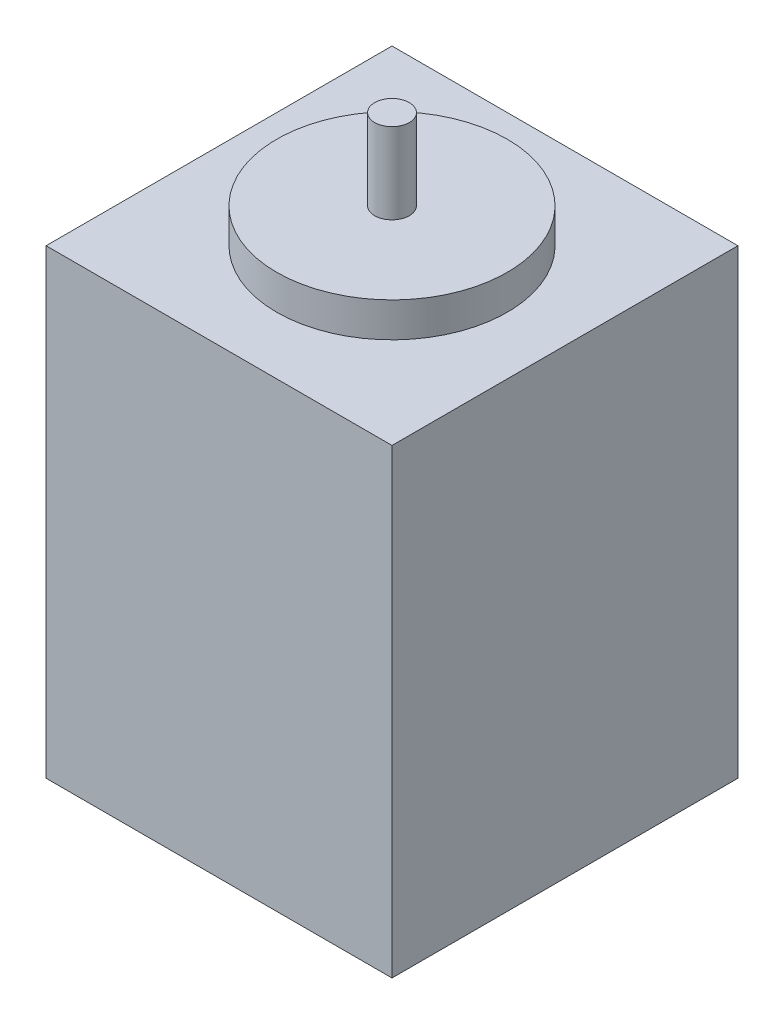
from build123d import *

# Parameters (mm, degrees)
SKETCH1_W           = 30
SKETCH1_H           = 30
BOSS_EXTRUDE1_DEPTH = 40
SKETCH2_R           = 1.5
BOSS_EXTRUDE2_DEPTH = 10
SKETCH4_R           = 10
BOSS_EXTRUDE3_DEPTH = 3


with BuildPart() as part:
    # Sketch1 → Boss-Extrude1 (new body)
    with BuildSketch(Plane(origin=(0, 0, 0), x_dir=(1, 0, 0), z_dir=(0, 1, 0))):
        with Locations((15, 15)):
            Rectangle(SKETCH1_W, SKETCH1_H)
    extrude(amount=BOSS_EXTRUDE1_DEPTH)

    # Sketch2 → Boss-Extrude2 (add)
    with BuildSketch(Plane(origin=(0, 40, 0), x_dir=(1, 0, 0), z_dir=(0, 1, 0))):
        with Locations((15, 15)):
            Circle(SKETCH2_R)
    extrude(amount=BOSS_EXTRUDE2_DEPTH)

    # Sketch4 → Boss-Extrude3 (add)
    with BuildSketch(Plane(origin=(0, 40, 0), x_dir=(1, 0, 0), z_dir=(0, 1, 0))):
        with Locations((15, 15)):
            Circle(SKETCH4_R)
    extrude(amount=BOSS_EXTRUDE3_DEPTH)


solid = part.part
